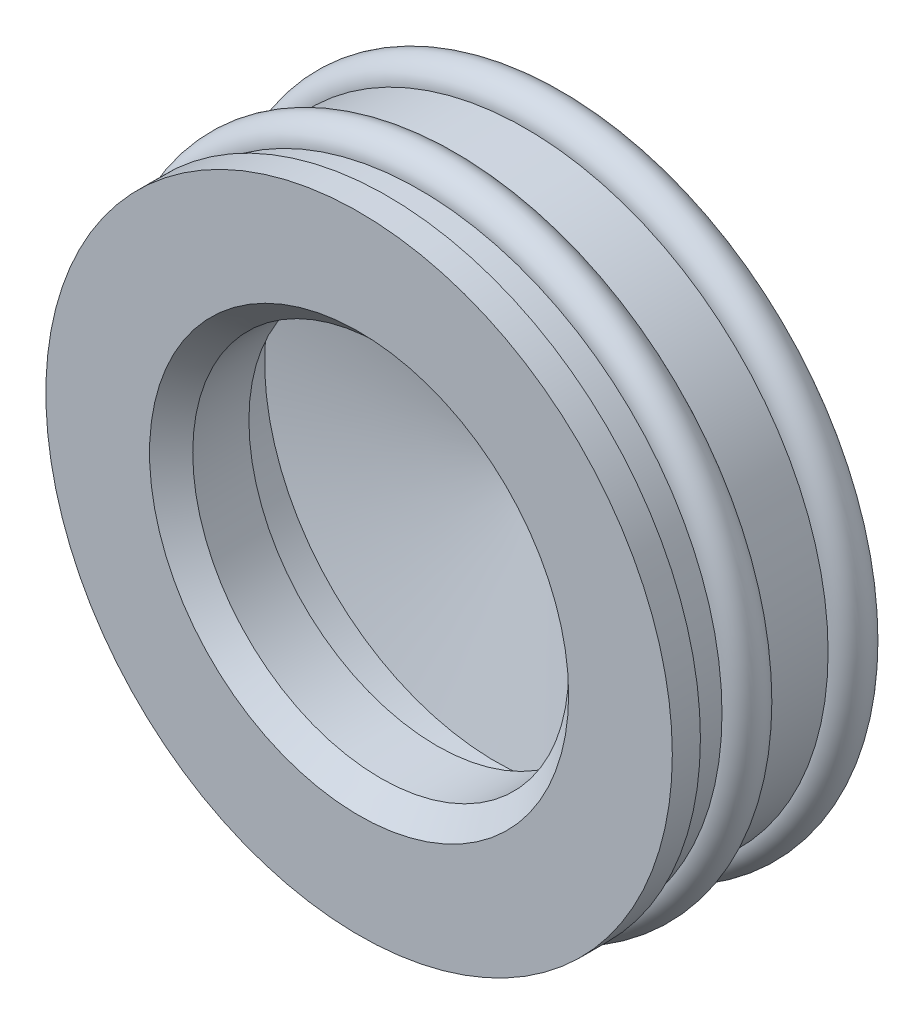
from build123d import *


with BuildPart() as part:
    # 草图1 → 旋转1 (revolve)
    with BuildSketch(Plane(origin=(0, 0, 0), x_dir=(1, 0, 0), z_dir=(0, 1, 0))):
        with BuildLine():
            Line((0, 12.802374441), (0, 8.802374441))
            ThreePointArc((0, 8.802374441), (0.35150636, 8.781710488), (0.698170379, 8.720003294))
            Line((0.698170379, 8.720003294), (10.7, 6.326627875))
            Line((10.7, 6.326627875), (10.7, 3.6))
            Line((10.7, 3.6), (8.7, 3.6))
            Line((8.7, 3.6), (8.7, 1))
            Line((8.7, 1), (9.7, 0))
            Line((9.7, 0), (14.5, 0))
            Line((14.5, 0), (14.5, 1.300002326))
            Line((14.5, 1.300002326), (14.000000007, 1.300002326))
            Line((14.000000007, 1.300002326), (14.000000007, 2.800002326))
            ThreePointArc((14.000000007, 2.800002326), (14.955727499, 3.755729817), (14.000000007, 4.711457309))
            Line((14.000000007, 4.711457309), (14.000000007, 7.711454982))
            ThreePointArc((14.000000007, 7.711454982), (14.948966073, 8.553699236), (14.225360777, 9.595959929))
            Line((14.225360777, 9.595959929), (1.629064218, 12.610175098))
            ThreePointArc((1.629064218, 12.610175098), (0.820181506, 12.75415855), (0, 12.802374441))
        make_face()
    revolve(axis=Axis((0, 0, -12.802374441), (0, 0, 1)))


solid = part.part
